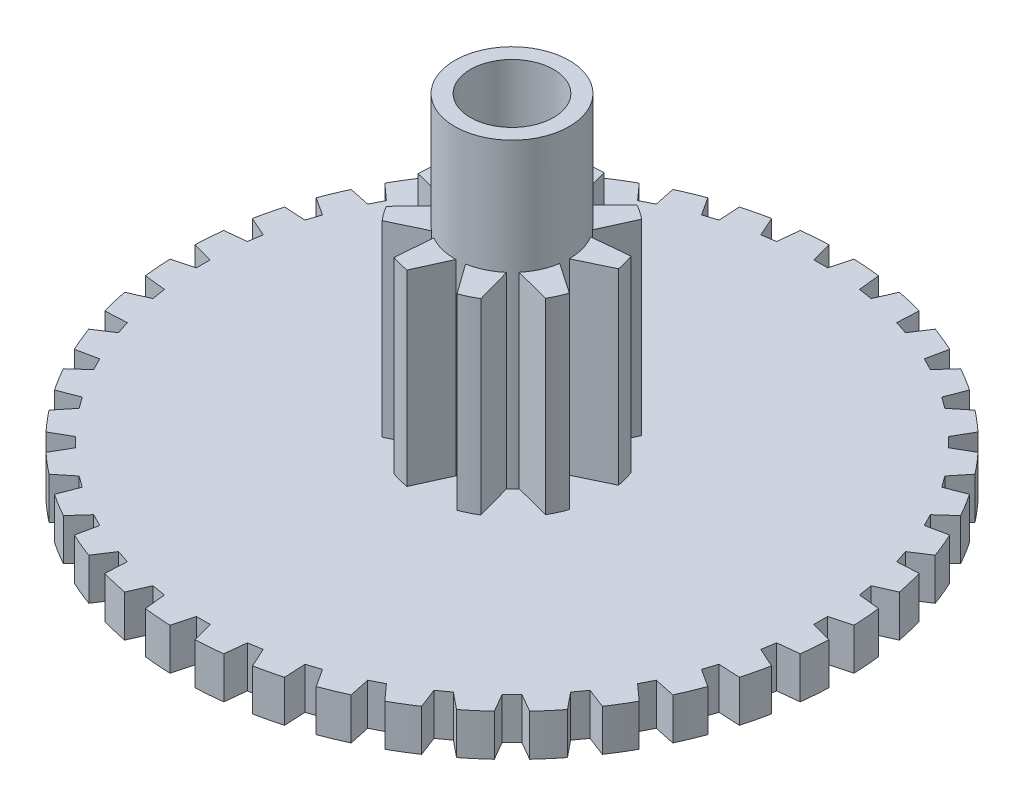
from build123d import *

# Parameters (mm, degrees)
BOSS_EXTRUDE1_DEPTH      = 0.6
BOSS_EXTRUDE2_DEPTH      = 2.7
SKETCH4_R                = 0.825
BOSS_EXTRUDE4_DEPTH      = 1.65
BOSS_EXTRUDE4_DEPTH_BACK = 4.25
SKETCH3_R                = 1.325
BOSS_EXTRUDE5_DEPTH      = 1
SKETCH5_R                = 0.6
CUT_EXTRUDE1_DEPTH       = 6


with BuildPart() as part:
    # Sketch1 → Boss-Extrude1 (new body)
    with BuildSketch(Plane(origin=(0, 0, 0), x_dir=(1, 0, 0), z_dir=(0, 1, 0))):
        with BuildLine():
            Line((-0.1, 4.448024184), (-0.18, 4.746588248))
            ThreePointArc((-0.18, 4.746588248), (-0.372680705, 4.735357335), (-0.564746092, 4.716308074))
            Line((-0.564746092, 4.716308074), (-0.59705545, 4.408905072))
            Line((-0.59705545, 4.408905072), (-0.794593118, 4.377618179))
            Line((-0.794593118, 4.377618179), (-0.920313895, 4.659991667))
            ThreePointArc((-0.920313895, 4.659991667), (-1.108865478, 4.618757122), (-1.295586261, 4.569896743))
            Line((-1.295586261, 4.569896743), (-1.279409413, 4.261224084))
            Line((-1.279409413, 4.261224084), (-1.469620716, 4.199420685))
            Line((-1.469620716, 4.199420685), (-1.637966607, 4.458650625))
            ThreePointArc((-1.637966607, 4.458650625), (-1.817746304, 4.388427779), (-1.994524797, 4.310959387))
            Line((-1.994524797, 4.310959387), (-1.93026007, 4.008617617))
            Line((-1.93026007, 4.008617617), (-2.108461374, 3.917819518))
            Line((-2.108461374, 3.917819518), (-2.315287145, 4.147522807))
            ThreePointArc((-2.315287145, 4.147522807), (-2.481868182, 4.050040781), (-2.644351512, 3.945871904))
            Line((-2.644351512, 3.945871904), (-2.533581318, 3.657305681))
            Line((-2.533581318, 3.657305681), (-2.695384717, 3.539748631))
            Line((-2.695384717, 3.539748631), (-2.93559763, 3.734269213))
            ThreePointArc((-2.93559763, 3.734269213), (-3.08487823, 3.611928337), (-3.229065517, 3.483623959))
            Line((-3.229065517, 3.483623959), (-3.074517385, 3.215938741))
            Line((-3.074517385, 3.215938741), (-3.215938741, 3.074517385))
            Line((-3.215938741, 3.074517385), (-3.483623959, 3.229065517))
            ThreePointArc((-3.483623959, 3.229065517), (-3.611928337, 3.08487823), (-3.734269213, 2.93559763))
            Line((-3.734269213, 2.93559763), (-3.539748631, 2.695384717))
            Line((-3.539748631, 2.695384717), (-3.657305681, 2.533581318))
            Line((-3.657305681, 2.533581318), (-3.945871904, 2.644351512))
            ThreePointArc((-3.945871904, 2.644351512), (-4.050040781, 2.481868182), (-4.147522807, 2.315287145))
            Line((-4.147522807, 2.315287145), (-3.917819518, 2.108461374))
            Line((-3.917819518, 2.108461374), (-4.008617617, 1.93026007))
            Line((-4.008617617, 1.93026007), (-4.310959387, 1.994524797))
            ThreePointArc((-4.310959387, 1.994524797), (-4.388427779, 1.817746304), (-4.458650625, 1.637966607))
            Line((-4.458650625, 1.637966607), (-4.199420685, 1.469620716))
            Line((-4.199420685, 1.469620716), (-4.261224084, 1.279409413))
            Line((-4.261224084, 1.279409413), (-4.569896743, 1.295586261))
            ThreePointArc((-4.569896743, 1.295586261), (-4.618757122, 1.108865478), (-4.659991667, 0.920313895))
            Line((-4.659991667, 0.920313895), (-4.377618179, 0.794593118))
            Line((-4.377618179, 0.794593118), (-4.408905072, 0.59705545))
            Line((-4.408905072, 0.59705545), (-4.716308074, 0.564746092))
            ThreePointArc((-4.716308074, 0.564746092), (-4.735357335, 0.372680705), (-4.746588248, 0.18))
            Line((-4.746588248, 0.18), (-4.448024184, 0.1))
            Line((-4.448024184, 0.1), (-4.448024184, -0.1))
            Line((-4.448024184, -0.1), (-4.746588248, -0.18))
            ThreePointArc((-4.746588248, -0.18), (-4.735357335, -0.372680705), (-4.716308074, -0.564746092))
            Line((-4.716308074, -0.564746092), (-4.408905072, -0.59705545))
            Line((-4.408905072, -0.59705545), (-4.377618179, -0.794593118))
            Line((-4.377618179, -0.794593118), (-4.659991667, -0.920313895))
            ThreePointArc((-4.659991667, -0.920313895), (-4.618757122, -1.108865478), (-4.569896743, -1.295586261))
            Line((-4.569896743, -1.295586261), (-4.261224084, -1.279409413))
            Line((-4.261224084, -1.279409413), (-4.199420685, -1.469620716))
            Line((-4.199420685, -1.469620716), (-4.458650625, -1.637966607))
            ThreePointArc((-4.458650625, -1.637966607), (-4.388427779, -1.817746304), (-4.310959387, -1.994524797))
            Line((-4.310959387, -1.994524797), (-4.008617617, -1.93026007))
            Line((-4.008617617, -1.93026007), (-3.917819518, -2.108461374))
            Line((-3.917819518, -2.108461374), (-4.147522807, -2.315287145))
            ThreePointArc((-4.147522807, -2.315287145), (-4.050040781, -2.481868182), (-3.945871904, -2.644351512))
            Line((-3.945871904, -2.644351512), (-3.657305681, -2.533581318))
            Line((-3.657305681, -2.533581318), (-3.539748631, -2.695384717))
            Line((-3.539748631, -2.695384717), (-3.734269213, -2.93559763))
            ThreePointArc((-3.734269213, -2.93559763), (-3.611928337, -3.08487823), (-3.483623959, -3.229065517))
            Line((-3.483623959, -3.229065517), (-3.215938741, -3.074517385))
            Line((-3.215938741, -3.074517385), (-3.074517385, -3.215938741))
            Line((-3.074517385, -3.215938741), (-3.229065517, -3.483623959))
            ThreePointArc((-3.229065517, -3.483623959), (-3.08487823, -3.611928337), (-2.93559763, -3.734269213))
            Line((-2.93559763, -3.734269213), (-2.695384717, -3.539748631))
            Line((-2.695384717, -3.539748631), (-2.533581318, -3.657305681))
            Line((-2.533581318, -3.657305681), (-2.644351512, -3.945871904))
            ThreePointArc((-2.644351512, -3.945871904), (-2.481868182, -4.050040781), (-2.315287145, -4.147522807))
            Line((-2.315287145, -4.147522807), (-2.108461374, -3.917819518))
            Line((-2.108461374, -3.917819518), (-1.93026007, -4.008617617))
            Line((-1.93026007, -4.008617617), (-1.994524797, -4.310959387))
            ThreePointArc((-1.994524797, -4.310959387), (-1.817746304, -4.388427779), (-1.637966607, -4.458650625))
            Line((-1.637966607, -4.458650625), (-1.469620716, -4.199420685))
            Line((-1.469620716, -4.199420685), (-1.279409413, -4.261224084))
            Line((-1.279409413, -4.261224084), (-1.295586261, -4.569896743))
            ThreePointArc((-1.295586261, -4.569896743), (-1.108865478, -4.618757122), (-0.920313895, -4.659991667))
            Line((-0.920313895, -4.659991667), (-0.794593118, -4.377618179))
            Line((-0.794593118, -4.377618179), (-0.59705545, -4.408905072))
            Line((-0.59705545, -4.408905072), (-0.564746092, -4.716308074))
            ThreePointArc((-0.564746092, -4.716308074), (-0.372680705, -4.735357335), (-0.18, -4.746588248))
            Line((-0.18, -4.746588248), (-0.1, -4.448024184))
            Line((-0.1, -4.448024184), (0.1, -4.448024184))
            Line((0.1, -4.448024184), (0.18, -4.746588248))
            ThreePointArc((0.18, -4.746588248), (0.372680705, -4.735357335), (0.564746092, -4.716308074))
            Line((0.564746092, -4.716308074), (0.59705545, -4.408905072))
            Line((0.59705545, -4.408905072), (0.794593118, -4.377618179))
            Line((0.794593118, -4.377618179), (0.920313895, -4.659991667))
            ThreePointArc((0.920313895, -4.659991667), (1.108865478, -4.618757122), (1.295586261, -4.569896743))
            Line((1.295586261, -4.569896743), (1.279409413, -4.261224084))
            Line((1.279409413, -4.261224084), (1.469620716, -4.199420685))
            Line((1.469620716, -4.199420685), (1.637966607, -4.458650625))
            ThreePointArc((1.637966607, -4.458650625), (1.817746304, -4.388427779), (1.994524797, -4.310959387))
            Line((1.994524797, -4.310959387), (1.93026007, -4.008617617))
            Line((1.93026007, -4.008617617), (2.108461374, -3.917819518))
            Line((2.108461374, -3.917819518), (2.315287145, -4.147522807))
            ThreePointArc((2.315287145, -4.147522807), (2.481868182, -4.050040781), (2.644351512, -3.945871904))
            Line((2.644351512, -3.945871904), (2.533581318, -3.657305681))
            Line((2.533581318, -3.657305681), (2.695384717, -3.539748631))
            Line((2.695384717, -3.539748631), (2.93559763, -3.734269213))
            ThreePointArc((2.93559763, -3.734269213), (3.08487823, -3.611928337), (3.229065517, -3.483623959))
            Line((3.229065517, -3.483623959), (3.074517385, -3.215938741))
            Line((3.074517385, -3.215938741), (3.215938741, -3.074517385))
            Line((3.215938741, -3.074517385), (3.483623959, -3.229065517))
            ThreePointArc((3.483623959, -3.229065517), (3.611928337, -3.08487823), (3.734269213, -2.93559763))
            Line((3.734269213, -2.93559763), (3.539748631, -2.695384717))
            Line((3.539748631, -2.695384717), (3.657305681, -2.533581318))
            Line((3.657305681, -2.533581318), (3.945871904, -2.644351512))
            ThreePointArc((3.945871904, -2.644351512), (4.050040781, -2.481868182), (4.147522807, -2.315287145))
            Line((4.147522807, -2.315287145), (3.917819518, -2.108461374))
            Line((3.917819518, -2.108461374), (4.008617617, -1.93026007))
            Line((4.008617617, -1.93026007), (4.310959387, -1.994524797))
            ThreePointArc((4.310959387, -1.994524797), (4.388427779, -1.817746304), (4.458650625, -1.637966607))
            Line((4.458650625, -1.637966607), (4.199420685, -1.469620716))
            Line((4.199420685, -1.469620716), (4.261224084, -1.279409413))
            Line((4.261224084, -1.279409413), (4.569896743, -1.295586261))
            ThreePointArc((4.569896743, -1.295586261), (4.618757122, -1.108865478), (4.659991667, -0.920313895))
            Line((4.659991667, -0.920313895), (4.377618179, -0.794593118))
            Line((4.377618179, -0.794593118), (4.408905072, -0.59705545))
            Line((4.408905072, -0.59705545), (4.716308074, -0.564746092))
            ThreePointArc((4.716308074, -0.564746092), (4.735357335, -0.372680705), (4.746588248, -0.18))
            Line((4.746588248, -0.18), (4.448024184, -0.1))
            Line((4.448024184, -0.1), (4.448024184, 0.1))
            Line((4.448024184, 0.1), (4.746588248, 0.18))
            ThreePointArc((4.746588248, 0.18), (4.735357335, 0.372680705), (4.716308074, 0.564746092))
            Line((4.716308074, 0.564746092), (4.408905072, 0.59705545))
            Line((4.408905072, 0.59705545), (4.377618179, 0.794593118))
            Line((4.377618179, 0.794593118), (4.659991667, 0.920313895))
            ThreePointArc((4.659991667, 0.920313895), (4.618757122, 1.108865478), (4.569896743, 1.295586261))
            Line((4.569896743, 1.295586261), (4.261224084, 1.279409413))
            Line((4.261224084, 1.279409413), (4.199420685, 1.469620716))
            Line((4.199420685, 1.469620716), (4.458650625, 1.637966607))
            ThreePointArc((4.458650625, 1.637966607), (4.388427779, 1.817746304), (4.310959387, 1.994524797))
            Line((4.310959387, 1.994524797), (4.008617617, 1.93026007))
            Line((4.008617617, 1.93026007), (3.917819518, 2.108461374))
            Line((3.917819518, 2.108461374), (4.147522807, 2.315287145))
            ThreePointArc((4.147522807, 2.315287145), (4.050040781, 2.481868182), (3.945871904, 2.644351512))
            Line((3.945871904, 2.644351512), (3.657305681, 2.533581318))
            Line((3.657305681, 2.533581318), (3.539748631, 2.695384717))
            Line((3.539748631, 2.695384717), (3.734269213, 2.93559763))
            ThreePointArc((3.734269213, 2.93559763), (3.611928337, 3.08487823), (3.483623959, 3.229065517))
            Line((3.483623959, 3.229065517), (3.215938741, 3.074517385))
            Line((3.215938741, 3.074517385), (3.074517385, 3.215938741))
            Line((3.074517385, 3.215938741), (3.229065517, 3.483623959))
            ThreePointArc((3.229065517, 3.483623959), (3.08487823, 3.611928337), (2.93559763, 3.734269213))
            Line((2.93559763, 3.734269213), (2.695384717, 3.539748631))
            Line((2.695384717, 3.539748631), (2.533581318, 3.657305681))
            Line((2.533581318, 3.657305681), (2.644351512, 3.945871904))
            ThreePointArc((2.644351512, 3.945871904), (2.481868182, 4.050040781), (2.315287145, 4.147522807))
            Line((2.315287145, 4.147522807), (2.108461374, 3.917819518))
            Line((2.108461374, 3.917819518), (1.93026007, 4.008617617))
            Line((1.93026007, 4.008617617), (1.994524797, 4.310959387))
            ThreePointArc((1.994524797, 4.310959387), (1.817746304, 4.388427779), (1.637966607, 4.458650625))
            Line((1.637966607, 4.458650625), (1.469620716, 4.199420685))
            Line((1.469620716, 4.199420685), (1.279409413, 4.261224084))
            Line((1.279409413, 4.261224084), (1.295586261, 4.569896743))
            ThreePointArc((1.295586261, 4.569896743), (1.108865478, 4.618757122), (0.920313895, 4.659991667))
            Line((0.920313895, 4.659991667), (0.794593118, 4.377618179))
            Line((0.794593118, 4.377618179), (0.59705545, 4.408905072))
            Line((0.59705545, 4.408905072), (0.564746092, 4.716308074))
            ThreePointArc((0.564746092, 4.716308074), (0.372680705, 4.735357335), (0.18, 4.746588248))
            Line((0.18, 4.746588248), (0.1, 4.448024184))
            Line((0.1, 4.448024184), (-0.1, 4.448024184))
        make_face()
    extrude(amount=BOSS_EXTRUDE1_DEPTH)

    # Sketch2 → Boss-Extrude2 (add)
    with BuildSketch(Plane(origin=(0, 0.6, 0), x_dir=(1, 0, 0), z_dir=(0, 1, 0))):
        with BuildLine():
            Line((0.150381327, 0.785738797), (0, 1.325))
            ThreePointArc((0, 1.325), (-0.128881922, 1.318716971), (-0.256541552, 1.299927472))
            Line((-0.256541552, 1.299927472), (-0.299667523, 0.741754255))
            Line((-0.299667523, 0.741754255), (-0.389864383, 0.698574092))
            Line((-0.389864383, 0.698574092), (-0.851693583, 1.015008887))
            ThreePointArc((-0.851693583, 1.015008887), (-0.94638421, 0.927352105), (-1.032099503, 0.830900485))
            Line((-1.032099503, 0.830900485), (-0.706349086, 0.375594154))
            Line((-0.706349086, 0.375594154), (-0.747688215, 0.284538807))
            Line((-0.747688215, 0.284538807), (-1.304870273, 0.230083835))
            ThreePointArc((-1.304870273, 0.230083835), (-1.321062808, 0.102068882), (-1.324726626, -0.026914073))
            Line((-1.324726626, -0.026914073), (-0.782522061, -0.166310626))
            Line((-0.782522061, -0.166310626), (-0.755660422, -0.262635349))
            Line((-0.755660422, -0.262635349), (-1.14748366, -0.6625))
            ThreePointArc((-1.14748366, -0.6625), (-1.077601436, -0.770973505), (-0.997499437, -0.872135237))
            Line((-0.997499437, -0.872135237), (-0.492544267, -0.630396816))
            Line((-0.492544267, -0.630396816), (-0.410050719, -0.686919506))
            Line((-0.410050719, -0.686919506), (-0.45317669, -1.245092723))
            ThreePointArc((-0.45317669, -1.245092723), (-0.329918376, -1.28326882), (-0.203531177, -1.309274631))
            Line((-0.203531177, -1.309274631), (0.027900464, -0.79951333))
            Line((0.027900464, -0.79951333), (0.127426273, -0.789786392))
            Line((0.127426273, -0.789786392), (0.45317669, -1.245092723))
            ThreePointArc((0.45317669, -1.245092723), (0.572137159, -1.195108393), (0.685671584, -1.133789874))
            Line((0.685671584, -1.133789874), (0.535290257, -0.594528671))
            Line((0.535290257, -0.594528671), (0.605279095, -0.523103448))
            Line((0.605279095, -0.523103448), (1.14748366, -0.6625))
            ThreePointArc((1.14748366, -0.6625), (1.206483359, -0.547743467), (1.25404099, -0.427792234))
            Line((1.25404099, -0.427792234), (0.79221179, -0.11135744))
            Line((0.79221179, -0.11135744), (0.799915102, -0.011654586))
            Line((0.799915102, -0.011654586), (1.304870273, 0.230083835))
            ThreePointArc((1.304870273, 0.230083835), (1.276302586, 0.355916715), (1.23563068, 0.478374146))
            Line((1.23563068, 0.478374146), (0.678448622, 0.423919175))
            Line((0.678448622, 0.423919175), (0.620261943, 0.505247585))
            Line((0.620261943, 0.505247585), (0.851693583, 1.015008887))
            ThreePointArc((0.851693583, 1.015008887), (0.748925649, 1.093039511), (0.639055042, 1.160703947))
            Line((0.639055042, 1.160703947), (0.247231804, 0.760839297))
            Line((0.247231804, 0.760839297), (0.150381327, 0.785738797))
        make_face()
    extrude(amount=BOSS_EXTRUDE2_DEPTH)

    # Sketch4 → Boss-Extrude4 (add, two sides)
    with BuildSketch(Plane(origin=(0, 3.3, 0), x_dir=(1, 0, 0), z_dir=(0, 1, 0))) as boss_extrude4_sk:
        Circle(SKETCH4_R)
    extrude(amount=BOSS_EXTRUDE4_DEPTH)
    extrude(boss_extrude4_sk.sketch, amount=-BOSS_EXTRUDE4_DEPTH_BACK)

    # Sketch3 → Boss-Extrude5 (add)
    with BuildSketch(Plane(origin=(0, 0.6, 0), x_dir=(1, 0, 0), z_dir=(0, 1, 0))):
        Circle(SKETCH3_R)
    extrude(amount=-BOSS_EXTRUDE5_DEPTH)

    # Sketch5 → Cut-Extrude1 (cut)
    with BuildSketch(Plane(origin=(0, 4.95, 0), x_dir=(1, 0, 0), z_dir=(0, 1, 0))):
        Circle(SKETCH5_R)
    extrude(amount=-CUT_EXTRUDE1_DEPTH, mode=Mode.SUBTRACT)


solid = part.part
